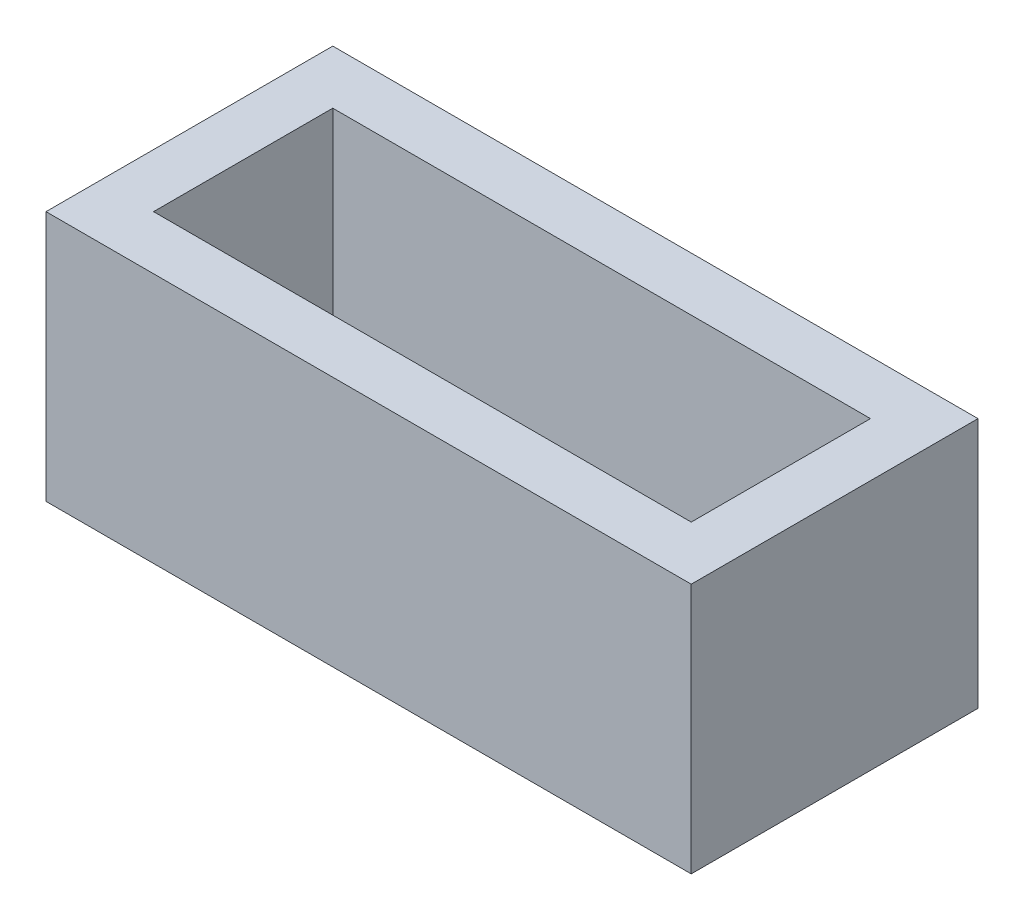
from build123d import *

# Parameters (mm, degrees)
SKETCH1_W           = 360
SKETCH1_H           = 160
SKETCH1_W_2         = 300
SKETCH1_H_2         = 100
BOSS_EXTRUDE1_DEPTH = 140


with BuildPart() as part:
    # Sketch1 → Boss-Extrude1 (new body)
    with BuildSketch(Plane(origin=(0, 0, 0), x_dir=(1, 0, 0), z_dir=(0, 1, 0))):
        with Locations((180, 80)):
            Rectangle(SKETCH1_W, SKETCH1_H)
        with Locations((180, 80)):
            Rectangle(SKETCH1_W_2, SKETCH1_H_2, mode=Mode.SUBTRACT)
    extrude(amount=BOSS_EXTRUDE1_DEPTH)


solid = part.part
